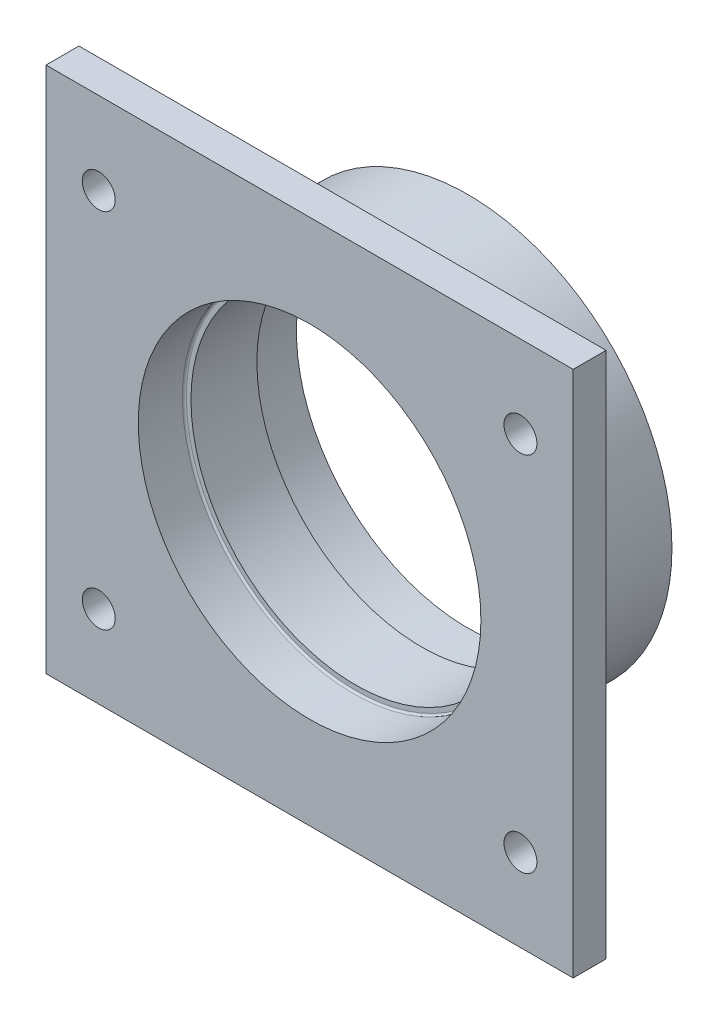
from build123d import *

# Parameters (mm, degrees)
SKETCH1_R             = 31
SKETCH1_R_2           = 26
BOSS_EXTRUDE1_DEPTH   = 7
SKETCH2_R             = 31
SKETCH2_R_2           = 25
BOSS_EXTRUDE3_DEPTH   = 10
SKETCH3_R             = 31
SKETCH3_R_2           = 26
BOSS_EXTRUDE4_DEPTH   = 7
FILLET1_R             = 0.3
SKETCH4_W             = 80
SKETCH4_H             = 80
SKETCH4_R             = 31
BOSS_EXTRUDE5_DEPTH   = 5
FILLET2_R             = 2
M6X1_0_TAPPED_HOLE1_D = 5


with BuildPart() as part:
    # Sketch1 → Boss-Extrude1 (new body)
    with BuildSketch(Plane.XY):
        Circle(SKETCH1_R)
        Circle(SKETCH1_R_2, mode=Mode.SUBTRACT)
    extrude(amount=BOSS_EXTRUDE1_DEPTH)

    # Sketch2 → Boss-Extrude3 (add)
    with BuildSketch(Plane.XY.offset(7)):
        Circle(SKETCH2_R)
        Circle(SKETCH2_R_2, mode=Mode.SUBTRACT)
    extrude(amount=BOSS_EXTRUDE3_DEPTH)

    # Sketch3 → Boss-Extrude4 (add)
    with BuildSketch(Plane.XY.offset(17)):
        Circle(SKETCH3_R)
        Circle(SKETCH3_R_2, mode=Mode.SUBTRACT)
    extrude(amount=BOSS_EXTRUDE4_DEPTH)

    # Fillet1
    fillet1_edges = [part.edges().sort_by_distance(p)[0] for p in [
        (-26, 0, 7),
        (-26, 0, 17),
    ]]
    fillet(fillet1_edges, radius=FILLET1_R)

    # Sketch4 → Boss-Extrude5 (add)
    with BuildSketch(Plane.XY.offset(24)):
        Rectangle(SKETCH4_W, SKETCH4_H)
        Circle(SKETCH4_R, mode=Mode.SUBTRACT)
    extrude(amount=-BOSS_EXTRUDE5_DEPTH)

    # Fillet2
    fillet2_edges = [part.edges().sort_by_distance(p)[0] for p in [
        (-31, 0, 19),
    ]]
    fillet(fillet2_edges, radius=FILLET2_R)

    # M6x1.0 Tapped Hole1 (through all)
    with Locations(Plane.XY.offset(24)):
        with Locations((-32, 27.5), (32, 27.5), (32, -27.5), (-32, -27.5)):
            Hole(M6X1_0_TAPPED_HOLE1_D / 2)


solid = part.part
